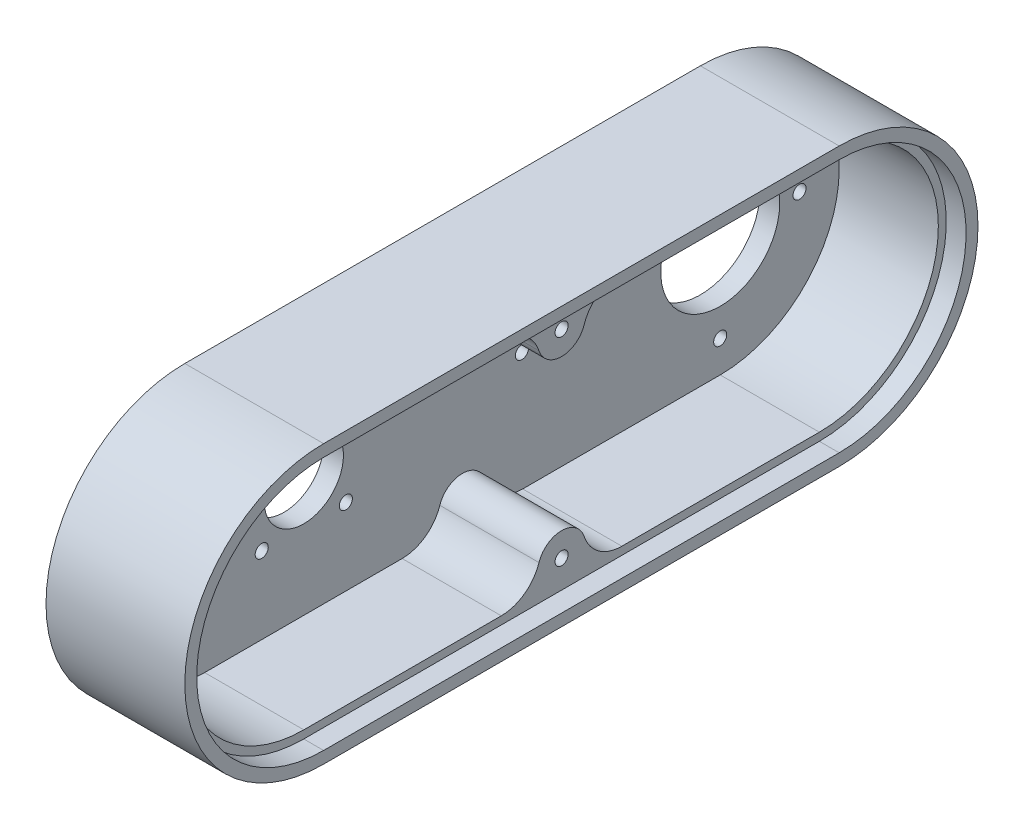
from build123d import *

# Parameters (mm, degrees)
EXTRUDE_1_DEPTH          = 35
SKETCH_2_R               = 10
SKETCH_2_R_2             = 15
CUT_EXTRUDE_1_DEPTH      = 1
CUT_EXTRUDE_1_DEPTH_BACK = 36
CUT_EXTRUDE_2_DEPTH      = 30
CUT_EXTRUDE_3_DEPTH      = 5
SKETCH_10_R              = 6
EXTRUDE_2_DEPTH          = 25
FILLET_1_R               = 10
HOLE_WIZARD_M4_1_D       = 3.3
HOLE_WIZARD_M4_1_DEPTH   = 11.5
HOLE_WIZARD_M4_1_TIP     = 0.991420021
HOLE_WIZARD_M4_2_D       = 3.3


with BuildPart() as part:
    # 스케치1 → 보스-돌출1 (new body)
    with BuildSketch(Plane(origin=(0, 0, 0), x_dir=(0, 0, -1), z_dir=(1, 0, 0))):
        with BuildLine():
            Line((-48.263014716, 12.710470067), (81.736985284, 12.710470067))
            ThreePointArc((81.736985284, 12.710470067), (116.736985284, -22.289529933), (81.736985284, -57.289529933))
            Line((81.736985284, -57.289529933), (-48.263014716, -57.289529933))
            ThreePointArc((-48.263014716, -57.289529933), (-83.263014716, -22.289529933), (-48.263014716, 12.710470067))
        make_face()
    extrude(amount=EXTRUDE_1_DEPTH)

    # 스케치2 → 컷-돌출1 (cut, two sides)
    with BuildSketch(Plane.ZY) as cut_extrude_1_sk:
        with Locations((23.263014716, -22.302890454)):
            Circle(SKETCH_2_R)
        with Locations((-81.736985284, -22.302890454)):
            Circle(SKETCH_2_R_2)
    extrude(amount=CUT_EXTRUDE_1_DEPTH, mode=Mode.SUBTRACT)
    extrude(cut_extrude_1_sk.sketch, amount=-CUT_EXTRUDE_1_DEPTH_BACK, mode=Mode.SUBTRACT)

    # 스케치3 → 컷-돌출2 (cut)
    with BuildSketch(Plane(origin=(35, 0, 0), x_dir=(0, 0, -1), z_dir=(1, 0, 0))):
        with BuildLine():
            Line((81.736985284, 7.710470067), (-48.263014716, 7.710470067))
            ThreePointArc((-48.263014716, 7.710470067), (-78.263014716, -22.289529933), (-48.263014716, -52.289529933))
            Line((-48.263014716, -52.289529933), (81.736985284, -52.289529933))
            ThreePointArc((81.736985284, -52.289529933), (111.736985284, -22.289529933), (81.736985284, 7.710470067))
        make_face()
    extrude(amount=-CUT_EXTRUDE_2_DEPTH, mode=Mode.SUBTRACT)

    # 스케치5 → 컷-돌출3 (cut)
    with BuildSketch(Plane(origin=(35, 0, 0), x_dir=(0, 0, -1), z_dir=(1, 0, 0))):
        with BuildLine():
            Line((-48.263014716, -54.289529933), (81.736985284, -54.289529933))
            ThreePointArc((81.736985284, -54.289529933), (113.736985284, -22.289529933), (81.736985284, 9.710470067))
            Line((81.736985284, 9.710470067), (-48.263014716, 9.710470067))
            ThreePointArc((-48.263014716, 9.710470067), (-80.263014716, -22.289529933), (-48.263014716, -54.289529933))
        make_face()
        with BuildLine():
            Line((-48.263014716, -52.289529933), (81.736985284, -52.289529933))
            ThreePointArc((81.736985284, -52.289529933), (111.736985284, -22.289529933), (81.736985284, 7.710470067))
            Line((81.736985284, 7.710470067), (-48.263014716, 7.710470067))
            ThreePointArc((-48.263014716, 7.710470067), (-78.263014716, -22.289529933), (-48.263014716, -52.289529933))
        make_face(mode=Mode.SUBTRACT)
    extrude(amount=-CUT_EXTRUDE_3_DEPTH, mode=Mode.SUBTRACT)

    # 스케치10 → 보스-돌출2 (add)
    with BuildSketch(Plane(origin=(5, 0, 0), x_dir=(0, 0, -1), z_dir=(1, 0, 0))):
        with Locations((16.736985284, 2.710470067)):
            Circle(SKETCH_10_R)
        with Locations((16.736985284, -47.289529933)):
            Circle(SKETCH_10_R)
    extrude(amount=EXTRUDE_2_DEPTH)

    # 필렛1
    fillet_1_edges = [part.edges().sort_by_distance(p)[0] for p in [
        (17.5, 7.710470067, -20.053610075),
        (17.5, 7.710470067, -13.420360494),
        (17.5, -52.289529933, -13.420360494),
        (17.5, -52.289529933, -20.053610075),
    ]]
    fillet(fillet_1_edges, radius=FILLET_1_R)

    # M4 나사 구멍1
    with Locations(Plane(origin=(30, 0, 0), x_dir=(0, 0, -1), z_dir=(1, 0, 0))):
        with Locations((16.736985284, 2.697109546), (16.736985284, -47.302890454)):
            Hole(HOLE_WIZARD_M4_1_D / 2, depth=HOLE_WIZARD_M4_1_DEPTH)
            with Locations((0, 0, -(HOLE_WIZARD_M4_1_DEPTH + HOLE_WIZARD_M4_1_TIP / 2))):  # 118° drill point
                Cone(0, HOLE_WIZARD_M4_1_D / 2, HOLE_WIZARD_M4_1_TIP, mode=Mode.SUBTRACT)

    # M4 나사 구멍2 (through all)
    with Locations(Plane(origin=(5, 0, 0), x_dir=(0, 0, -1), z_dir=(1, 0, 0))):
        with Locations((-33.869616434, -11.696288736), (-12.656412998, -11.696288736), (-12.656412998, -32.909492171), (-33.869616434, -32.909492171), (-53.263014716, -37.302890454), (-53.263014716, -22.302890454), (-53.263014716, -7.302890454), (81.736985284, -0.302890454), (101.736985284, -22.302890454), (81.736985284, -44.302890454), (31.736985284, -22.302890454)):
            Hole(HOLE_WIZARD_M4_2_D / 2)


solid = part.part
